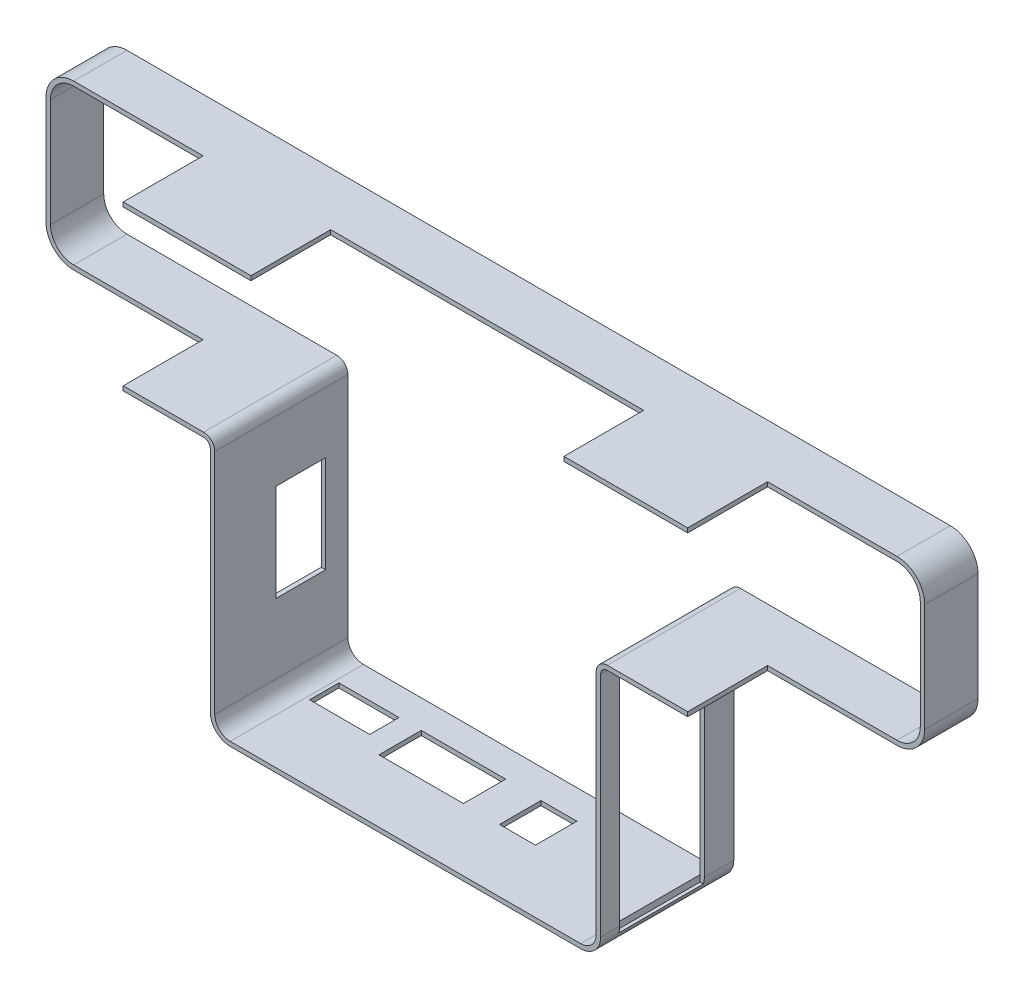
from build123d import *

# Parameters (mm, degrees)
AUFSATZ_LINEAR_AUSTRAGEN1_DEPTH = 30
SKIZZE4_W                       = 19.059709953
SKIZZE4_H                       = 53.604548155
SCHNITT_LINEAR_AUSTRAGEN1_DEPTH = 1
SKIZZE5_W                       = 13.535379209
SKIZZE5_H                       = 6.598473738
SKIZZE5_W_2                     = 19.010784176
SKIZZE5_H_2                     = 9.525951679
SKIZZE5_W_3                     = 8.081851555
SKIZZE5_H_3                     = 9.33
SCHNITT_LINEAR_AUSTRAGEN2_DEPTH = 1
SKIZZE6_W                       = 11.254395851
SKIZZE6_H                       = 21.878706828
SCHNITT_LINEAR_AUSTRAGEN3_DEPTH = 1
SKIZZE8_W                       = 70.5
SKIZZE8_H                       = 18.817969375
SCHNITT_LINEAR_AUSTRAGEN4_DEPTH = 1
SCHNITT_LINEAR_AUSTRAGEN5_DEPTH = 18


with BuildPart() as part:
    # Skizze2 → Aufsatz-Linear austragen1 (new body)
    with BuildSketch(Plane(origin=(0, 0, 188.684819625), x_dir=(-1, 0, 0), z_dir=(0, 0, -1))):
        with BuildLine():
            Line((114.255256192, 57.804225359), (-71.202450647, 57.804225359))
            ThreePointArc((-71.202450647, 57.804225359), (-75.616222333, 55.975981265), (-77.444466427, 51.562209578))
            Line((-77.444466427, 51.562209578), (-77.444466427, 27.181394091))
            ThreePointArc((-77.444466427, 27.181394091), (-75.616222333, 22.767622404), (-71.202450647, 20.93937831))
            Line((-71.202450647, 20.93937831), (-23.9356809, 20.93937831))
            ThreePointArc((-23.9356809, 20.93937831), (-22.875020729, 20.500038482), (-22.4356809, 19.43937831))
            Line((-22.4356809, 19.43937831), (-22.4356809, -31.865246208))
            ThreePointArc((-22.4356809, -31.865246208), (-21.117661416, -35.047226723), (-17.9356809, -36.365246208))
            Line((-17.9356809, -36.365246208), (60.988486446, -36.365246208))
            ThreePointArc((60.988486446, -36.365246208), (64.170466961, -35.047226723), (65.488486446, -31.865246208))
            Line((65.488486446, -31.865246208), (65.488486446, 19.43937831))
            ThreePointArc((65.488486446, 19.43937831), (65.927826274, 20.500038482), (66.988486446, 20.93937831))
            Line((66.988486446, 20.93937831), (114.255256192, 20.93937831))
            ThreePointArc((114.255256192, 20.93937831), (118.669027879, 22.767622404), (120.497271973, 27.181394091))
            Line((120.497271973, 27.181394091), (120.497271973, 51.562209578))
            ThreePointArc((120.497271973, 51.562209578), (118.669027879, 55.975981265), (114.255256192, 57.804225359))
        make_face()
        with BuildLine():
            Line((114.255256192, 56.804225359), (-71.202450647, 56.804225359))
            ThreePointArc((-71.202450647, 56.804225359), (-74.909115552, 55.268874484), (-76.444466427, 51.562209578))
            Line((-76.444466427, 51.562209578), (-76.444466427, 27.181394091))
            ThreePointArc((-76.444466427, 27.181394091), (-74.909115552, 23.474729185), (-71.202450647, 21.93937831))
            Line((-71.202450647, 21.93937831), (-23.9356809, 21.93937831))
            ThreePointArc((-23.9356809, 21.93937831), (-22.167913947, 21.207145263), (-21.4356809, 19.43937831))
            Line((-21.4356809, 19.43937831), (-21.4356809, -31.865246208))
            ThreePointArc((-21.4356809, -31.865246208), (-20.410554634, -34.340119942), (-17.9356809, -35.365246208))
            Line((-17.9356809, -35.365246208), (60.988486446, -35.365246208))
            ThreePointArc((60.988486446, -35.365246208), (63.46336018, -34.340119942), (64.488486446, -31.865246208))
            Line((64.488486446, -31.865246208), (64.488486446, 19.43937831))
            ThreePointArc((64.488486446, 19.43937831), (65.220719493, 21.207145263), (66.988486446, 21.93937831))
            Line((66.988486446, 21.93937831), (114.255256192, 21.93937831))
            ThreePointArc((114.255256192, 21.93937831), (117.961921098, 23.474729185), (119.497271973, 27.181394091))
            Line((119.497271973, 27.181394091), (119.497271973, 51.562209578))
            ThreePointArc((119.497271973, 51.562209578), (117.961921098, 55.268874484), (114.255256192, 56.804225359))
        make_face(mode=Mode.SUBTRACT)
    extrude(amount=-AUFSATZ_LINEAR_AUSTRAGEN1_DEPTH)

    # Skizze4 → Schnitt-Linear austragen1 (cut)
    with BuildSketch(Plane(origin=(22.4356809, 0, 0), x_dir=(0, 0, -1), z_dir=(1, 0, 0))):
        with Locations((-204.849070455, -6.494967379)):
            Rectangle(SKIZZE4_W, SKIZZE4_H)
    extrude(amount=-SCHNITT_LINEAR_AUSTRAGEN1_DEPTH, mode=Mode.SUBTRACT)

    # Skizze5 → Schnitt-Linear austragen2 (cut)
    with BuildSketch(Plane.XZ.offset(36.365246208)):
        with Locations((-53.389754229, 198.342500668)):
            Rectangle(SKIZZE5_W, SKIZZE5_H)
        with Locations((-32.103878534, 199.806239639)):
            Rectangle(SKIZZE5_W_2, SKIZZE5_H_2)
        with Locations((-10.407185504, 199.904215478)):
            Rectangle(SKIZZE5_W_3, SKIZZE5_H_3)
    extrude(amount=-SCHNITT_LINEAR_AUSTRAGEN2_DEPTH, mode=Mode.SUBTRACT)

    # Skizze6 → Schnitt-Linear austragen3 (cut)
    with BuildSketch(Plane.ZY.offset(65.488486446)):
        with Locations((199.312017551, -5.205318356)):
            Rectangle(SKIZZE6_W, SKIZZE6_H)
    extrude(amount=-SCHNITT_LINEAR_AUSTRAGEN3_DEPTH, mode=Mode.SUBTRACT)

    # Skizze8 → Schnitt-Linear austragen4 (cut)
    with BuildSketch(Plane(origin=(0, 57.804225359, 0), x_dir=(1, 0, 0), z_dir=(0, 1, 0))):
        with Locations((-21.082442705, -210.135508824)):
            Rectangle(SKIZZE8_W, SKIZZE8_H)
    extrude(amount=-SCHNITT_LINEAR_AUSTRAGEN4_DEPTH, mode=Mode.SUBTRACT)

    # Skizze9 → Schnitt-Linear austragen5 (cut)
    with BuildSketch(Plane.XY.offset(218.684819625)):
        with BuildLine():
            Line((77.444466427, 51.562209578), (77.444466427, 27.181394091))
            ThreePointArc((77.444466427, 27.181394091), (75.616222333, 22.767622404), (71.202450647, 20.93937831))
            Line((71.202450647, 20.93937831), (42.046255802, 20.93937831))
            Line((42.046255802, 20.93937831), (42.046255802, 57.804225359))
            Line((42.046255802, 57.804225359), (71.202450647, 57.804225359))
            ThreePointArc((71.202450647, 57.804225359), (75.616222333, 55.975981265), (77.444466427, 51.562209578))
        make_face()
        with BuildLine():
            Line((-85.099061347, 57.804225359), (-85.099061347, 20.93937831))
            Line((-85.099061347, 20.93937831), (-114.255256192, 20.93937831))
            ThreePointArc((-114.255256192, 20.93937831), (-118.669027879, 22.767622404), (-120.497271973, 27.181394091))
            Line((-120.497271973, 27.181394091), (-120.497271973, 51.562209578))
            ThreePointArc((-120.497271973, 51.562209578), (-118.669027879, 55.975981265), (-114.255256192, 57.804225359))
            Line((-114.255256192, 57.804225359), (-85.099061347, 57.804225359))
        make_face()
    extrude(amount=-SCHNITT_LINEAR_AUSTRAGEN5_DEPTH, mode=Mode.SUBTRACT)


solid = part.part
